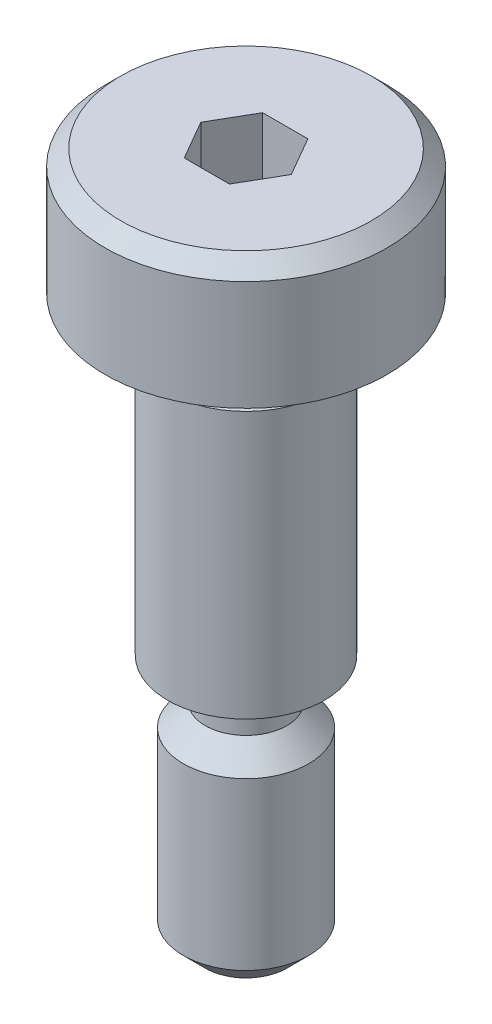
from build123d import *

# Parameters (mm, degrees)
CUT_EXTRUDE1_DEPTH = 3


with BuildPart() as part:
    # Sketch1 → Revolve1 (revolve)
    with BuildSketch(Plane.XY):
        with BuildLine():
            Line((0, 0), (0, 22))
            Line((0, 22), (4, 22))
            Line((4, 22), (4.5, 21.5))
            Line((4.5, 21.5), (4.5, 18))
            Line((4.5, 18), (2.5, 18))
            ThreePointArc((2.5, 18), (2.146446609, 17.853553391), (2, 17.5))
            Line((2, 17.5), (2, 17))
            Line((2, 17), (2.5, 16.5))
            Line((2.5, 16.5), (2.5, 8))
            Line((2.5, 8), (2, 8))
            ThreePointArc((2, 8), (1.505025253, 7.794974747), (1.3, 7.3))
            Line((1.3, 7.3), (1.3, 6.7))
            Line((1.3, 6.7), (2, 6))
            Line((2, 6), (2, 0.7))
            Line((2, 0.7), (1.3, 0))
            Line((1.3, 0), (0, 0))
        make_face()
    revolve(axis=Axis((0, 0, 0), (0, 1, 0)))

    # Sketch2 → Cut-Extrude1 (cut)
    with BuildSketch(Plane(origin=(0, 22, 0), x_dir=(1, 0, 0), z_dir=(0, 1, 0))):
        Polygon((0.721687836, 1.25), (-0.721687836, 1.25), (-1.443375673, 0), (-0.721687836, -1.25), (0.721687836, -1.25), (1.443375673, 0), align=None)
    extrude(amount=-CUT_EXTRUDE1_DEPTH, mode=Mode.SUBTRACT)


solid = part.part
